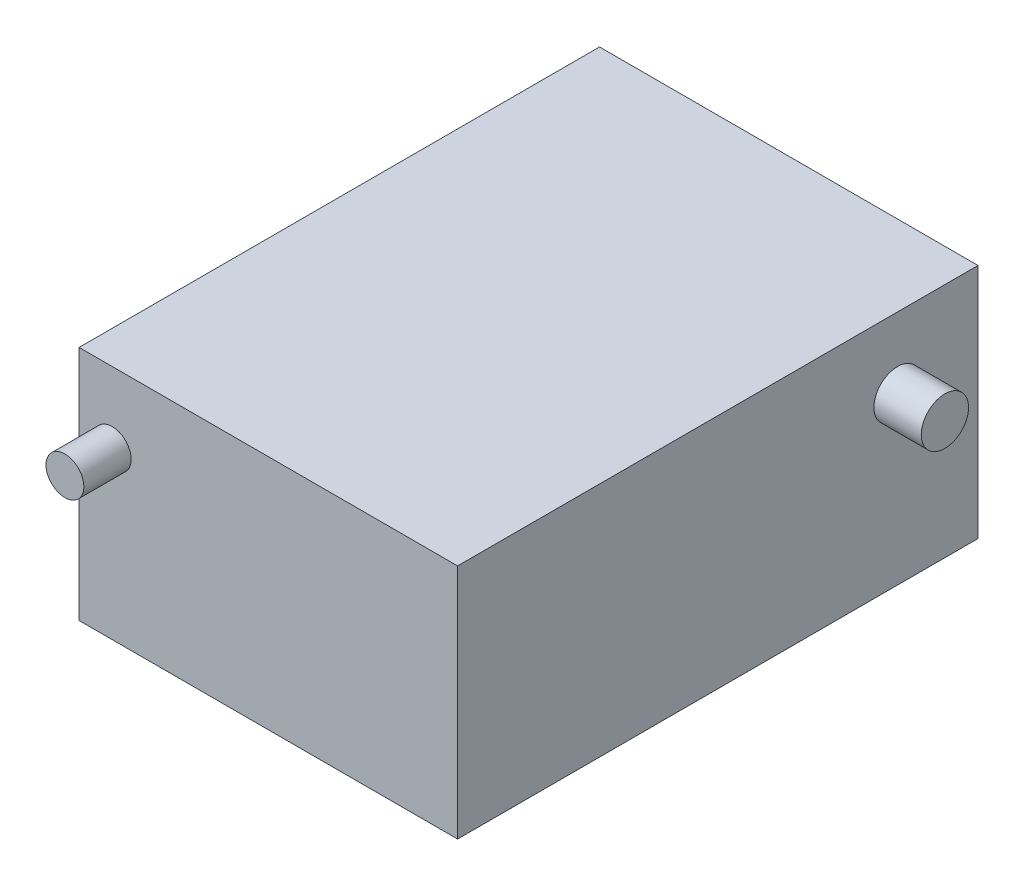
from build123d import *

# Parameters (mm, degrees)
SKETCH1_W           = 110
SKETCH1_H           = 50
BOSS_EXTRUDE1_DEPTH = 80
SKETCH2_R           = 4
BOSS_EXTRUDE2_DEPTH = 10
SKETCH3_R           = 5
BOSS_EXTRUDE3_DEPTH = 10


with BuildPart() as part:
    # Sketch1 → Boss-Extrude1 (new body)
    with BuildSketch(Plane(origin=(0, 0, 0), x_dir=(0, 0, -1), z_dir=(1, 0, 0))):
        with Locations((55, 25)):
            Rectangle(SKETCH1_W, SKETCH1_H)
    extrude(amount=BOSS_EXTRUDE1_DEPTH)

    # Sketch2 → Boss-Extrude2 (add)
    with BuildSketch(Plane.XY):
        with Locations((7, 35)):
            Circle(SKETCH2_R)
    extrude(amount=BOSS_EXTRUDE2_DEPTH)

    # Sketch3 → Boss-Extrude3 (add)
    with BuildSketch(Plane(origin=(80, 0, 0), x_dir=(0, 0, -1), z_dir=(1, 0, 0))):
        with Locations((93, 35)):
            Circle(SKETCH3_R)
    extrude(amount=BOSS_EXTRUDE3_DEPTH)


solid = part.part
